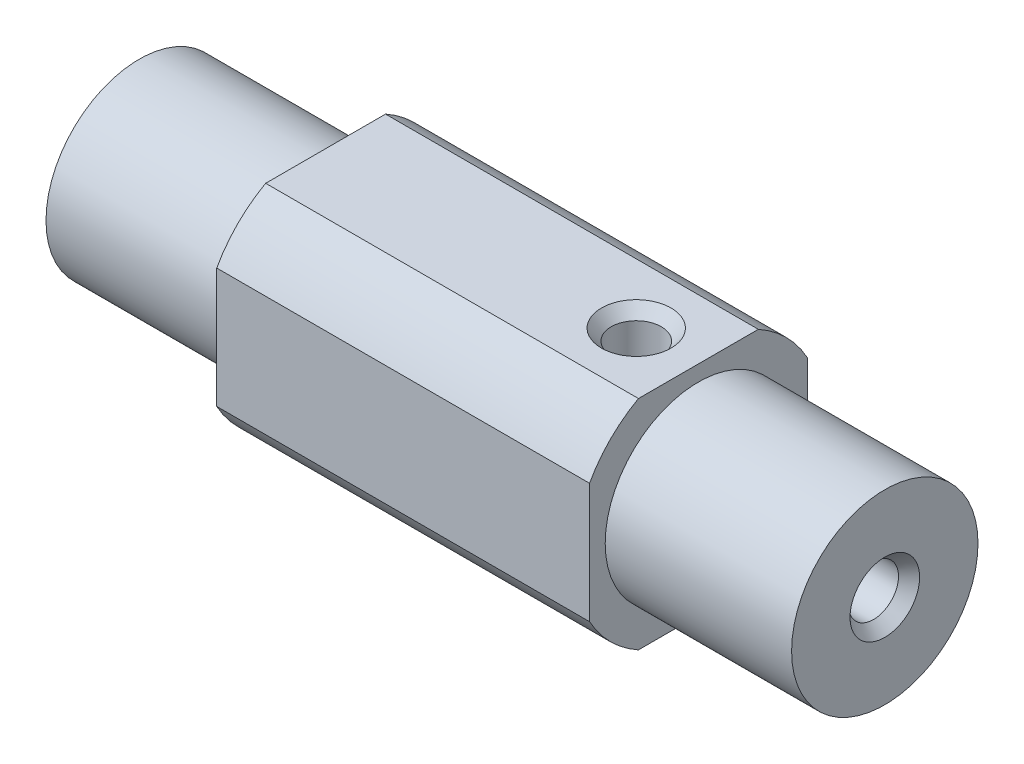
from build123d import *

# Parameters (mm, degrees)
SKETCH1_R                         = 12.7
BOSS_EXTRUDE1_DEPTH               = 79.375
SKETCH2_R                         = 21.293421543
SKETCH2_R_2                       = 9.525
CUT_EXTRUDE1_DEPTH                = 19.05
SKETCH3_W                         = 88.347660667
SKETCH3_H                         = 62.084650607
CUT_EXTRUDE2_DEPTH                = 7.62
SKETCH7_W                         = 118.824828897
SKETCH7_H                         = 51.847980611
CUT_EXTRUDE5_DEPTH                = 25.4
F_1_4_20_TAPPED_HOLE2_D           = 5.1054
F_1_4_20_TAPPED_HOLE2_DEPTH       = 16.002
F_1_4_20_TAPPED_HOLE2_CSINK_D     = 7.112
F_1_4_20_TAPPED_HOLE2_CSINK_ANGLE = 82
F_1_4_20_TAPPED_HOLE2_TIP         = 1.533816902
F_1_4_20_TAPPED_HOLE3_D           = 5.1054
F_1_4_20_TAPPED_HOLE3_DEPTH       = 16.002
F_1_4_20_TAPPED_HOLE3_CSINK_D     = 7.112
F_1_4_20_TAPPED_HOLE3_CSINK_ANGLE = 82
F_1_4_20_TAPPED_HOLE3_TIP         = 1.533816902
CUT_EXTRUDE10_DEPTH               = 88.9
SKETCH18_R                        = 21.68820387
CUT_EXTRUDE12_DEPTH               = 3.175
SKETCH30_R                        = 17.847306034
SKETCH30_R_2                      = 9.525
CUT_EXTRUDE13_DEPTH               = 19.05
F_1_4_20_TAPPED_HOLE6_D           = 5.1054
F_1_4_20_TAPPED_HOLE6_DEPTH       = 16.002
F_1_4_20_TAPPED_HOLE6_CSINK_D     = 7.112
F_1_4_20_TAPPED_HOLE6_CSINK_ANGLE = 82
F_1_4_20_TAPPED_HOLE6_TIP         = 1.533816902
F_1_4_20_TAPPED_HOLE7_D           = 5.1054
F_1_4_20_TAPPED_HOLE7_DEPTH       = 16.002
F_1_4_20_TAPPED_HOLE7_CSINK_D     = 7.112
F_1_4_20_TAPPED_HOLE7_CSINK_ANGLE = 82
F_1_4_20_TAPPED_HOLE7_TIP         = 1.533816902


with BuildPart() as part:
    # Sketch1 → Boss-Extrude1 (new body)
    with BuildSketch(Plane(origin=(0, 0, 0), x_dir=(0, 0, -1), z_dir=(1, 0, 0))):
        Circle(SKETCH1_R)
    extrude(amount=-BOSS_EXTRUDE1_DEPTH)

    # Sketch2 → Cut-Extrude1 (cut)
    with BuildSketch(Plane(origin=(0, 0, 0), x_dir=(0, 0, -1), z_dir=(1, 0, 0))):
        Circle(SKETCH2_R)
        Circle(SKETCH2_R_2, mode=Mode.SUBTRACT)
    extrude(amount=-CUT_EXTRUDE1_DEPTH, mode=Mode.SUBTRACT)

    # Sketch3 → Cut-Extrude2 (cut)
    with BuildSketch(Plane(origin=(0, 12.401228443, 11.1252), x_dir=(1, 0, 0), z_dir=(0, 0, 1))):
        with Locations((-47.069787049, -6.880973923)):
            Rectangle(SKETCH3_W, SKETCH3_H)
    extrude(amount=CUT_EXTRUDE2_DEPTH, mode=Mode.SUBTRACT)

    # Sketch7 → Cut-Extrude5 (cut)
    with BuildSketch(Plane(origin=(0, 11.1252, 0), x_dir=(-1, 0, 0), z_dir=(0, 1, 0))):
        with Locations((37.000899043, -1.114295637)):
            Rectangle(SKETCH7_W, SKETCH7_H)
    extrude(amount=CUT_EXTRUDE5_DEPTH, mode=Mode.SUBTRACT)

    # 1/4-20 Tapped Hole2
    with Locations(Plane(origin=(0, 11.1252, 0), x_dir=(-1, 0, 0), z_dir=(0, 1, 0))):
        with Locations((25.4, 0)):
            CounterSinkHole(F_1_4_20_TAPPED_HOLE2_D / 2, F_1_4_20_TAPPED_HOLE2_CSINK_D / 2, depth=F_1_4_20_TAPPED_HOLE2_DEPTH, counter_sink_angle=F_1_4_20_TAPPED_HOLE2_CSINK_ANGLE)
            with Locations((0, 0, -(F_1_4_20_TAPPED_HOLE2_DEPTH + F_1_4_20_TAPPED_HOLE2_TIP / 2))):  # 118° drill point
                Cone(0, F_1_4_20_TAPPED_HOLE2_D / 2, F_1_4_20_TAPPED_HOLE2_TIP, mode=Mode.SUBTRACT)

    # 1/4-20 Tapped Hole3
    with Locations(Plane(origin=(0, 0, 0), x_dir=(0, 0, -1), z_dir=(1, 0, 0))):
        with Locations((0, 0)):
            CounterSinkHole(F_1_4_20_TAPPED_HOLE3_D / 2, F_1_4_20_TAPPED_HOLE3_CSINK_D / 2, depth=F_1_4_20_TAPPED_HOLE3_DEPTH, counter_sink_angle=F_1_4_20_TAPPED_HOLE3_CSINK_ANGLE)
            with Locations((0, 0, -(F_1_4_20_TAPPED_HOLE3_DEPTH + F_1_4_20_TAPPED_HOLE3_TIP / 2))):  # 118° drill point
                Cone(0, F_1_4_20_TAPPED_HOLE3_D / 2, F_1_4_20_TAPPED_HOLE3_TIP, mode=Mode.SUBTRACT)

    # Sketch26 → Cut-Extrude10 (cut)
    with BuildSketch(Plane(origin=(0, 0, 0), x_dir=(0, 0, -1), z_dir=(1, 0, 0))):
        Polygon((-14.121239211, -11.1252), (11.1252, -11.1252), (11.1252, 12.077626787), (19.494279453, 12.077626787), (19.494279453, -11.628277338), (15.190001849, -11.628277338), (15.190001849, -15.796314113), (-14.121239211, -15.796314113), align=None)
    extrude(amount=-CUT_EXTRUDE10_DEPTH, mode=Mode.SUBTRACT)

    # Sketch18 → Cut-Extrude12 (cut)
    with BuildSketch(Plane.ZY.offset(79.375)):
        Circle(SKETCH18_R)
    extrude(amount=-CUT_EXTRUDE12_DEPTH, mode=Mode.SUBTRACT)

    # Sketch30 → Cut-Extrude13 (cut)
    with BuildSketch(Plane.ZY.offset(76.2)):
        Circle(SKETCH30_R)
        Circle(SKETCH30_R_2, mode=Mode.SUBTRACT)
    extrude(amount=-CUT_EXTRUDE13_DEPTH, mode=Mode.SUBTRACT)

    # 1/4-20 Tapped Hole6
    with Locations(Plane.ZY.offset(76.2)):
        with Locations((0, 0)):
            CounterSinkHole(F_1_4_20_TAPPED_HOLE6_D / 2, F_1_4_20_TAPPED_HOLE6_CSINK_D / 2, depth=F_1_4_20_TAPPED_HOLE6_DEPTH, counter_sink_angle=F_1_4_20_TAPPED_HOLE6_CSINK_ANGLE)
            with Locations((0, 0, -(F_1_4_20_TAPPED_HOLE6_DEPTH + F_1_4_20_TAPPED_HOLE6_TIP / 2))):  # 118° drill point
                Cone(0, F_1_4_20_TAPPED_HOLE6_D / 2, F_1_4_20_TAPPED_HOLE6_TIP, mode=Mode.SUBTRACT)

    # 1/4-20 Tapped Hole7
    with Locations(Plane.XZ.offset(11.1252)):
        with Locations((-50.8, 0)):
            CounterSinkHole(F_1_4_20_TAPPED_HOLE7_D / 2, F_1_4_20_TAPPED_HOLE7_CSINK_D / 2, depth=F_1_4_20_TAPPED_HOLE7_DEPTH, counter_sink_angle=F_1_4_20_TAPPED_HOLE7_CSINK_ANGLE)
            with Locations((0, 0, -(F_1_4_20_TAPPED_HOLE7_DEPTH + F_1_4_20_TAPPED_HOLE7_TIP / 2))):  # 118° drill point
                Cone(0, F_1_4_20_TAPPED_HOLE7_D / 2, F_1_4_20_TAPPED_HOLE7_TIP, mode=Mode.SUBTRACT)


solid = part.part
